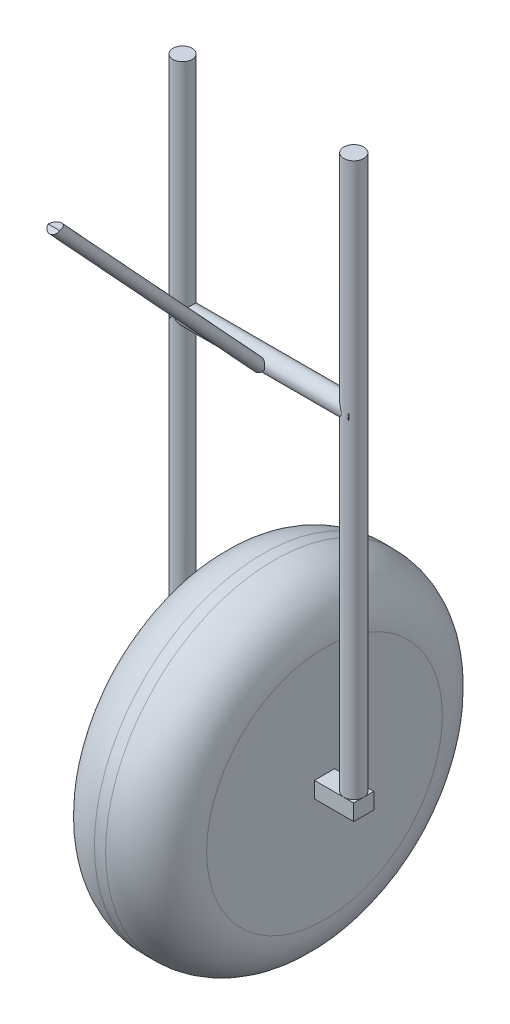
from build123d import *

# Parameters (mm, degrees)
IZIM1_R                          = 3
Y_KSEKLIK_EKSTR_ZYON1_DEPTH      = 1
Y_KSEKLIK_EKSTR_ZYON1_DEPTH_BACK = 1
RADYUS1_R                        = 0.9
RADYUS2_R                        = 0.9
IZIM2_W                          = 0.358194198
IZIM2_H                          = 0.28655536
Y_KSEKLIK_EKSTR_ZYON2_DEPTH      = 0.7
Y_KSEKLIK_EKSTR_ZYON2_DEPTH_BACK = 2.7
IZIM3_R                          = 0.171322749
IZIM3_R_2                        = 0.177674655
Y_KSEKLIK_EKSTR_ZYON3_DEPTH      = 10
IZIM5_R                          = 0.171322749
Y_KSEKLIK_EKSTR_ZYON4_DEPTH      = 1.6
Y_KSEKLIK_EKSTR_ZYON4_DEPTH_BACK = 1.6
KES_EKSTR_ZYON1_DEPTH            = 1.6


with BuildPart() as part:
    # izim1 → Y_kseklik-Ekstr_zyon1 (new body, two sides)
    with BuildSketch(Plane(origin=(0, 0, 0), x_dir=(0, 0, -1), z_dir=(1, 0, 0))) as y_kseklik_ekstr_zyon1_sk:
        Circle(IZIM1_R)
    extrude(amount=Y_KSEKLIK_EKSTR_ZYON1_DEPTH)
    extrude(y_kseklik_ekstr_zyon1_sk.sketch, amount=-Y_KSEKLIK_EKSTR_ZYON1_DEPTH_BACK)

    # Radyus1
    radyus1_edges = [part.edges().sort_by_distance(p)[0] for p in [
        (-1, 0, 3),
    ]]
    fillet(radyus1_edges, radius=RADYUS1_R)

    # Radyus2
    radyus2_edges = [part.edges().sort_by_distance(p)[0] for p in [
        (1, 0, 3),
    ]]
    fillet(radyus2_edges, radius=RADYUS2_R)

    # izim2 → Y_kseklik-Ekstr_zyon2 (add, two sides)
    with BuildSketch(Plane(origin=(1, 0, 0), x_dir=(0, 0, -1), z_dir=(1, 0, 0))) as y_kseklik_ekstr_zyon2_sk:
        Rectangle(IZIM2_W, IZIM2_H)
    extrude(amount=Y_KSEKLIK_EKSTR_ZYON2_DEPTH)
    extrude(y_kseklik_ekstr_zyon2_sk.sketch, amount=-Y_KSEKLIK_EKSTR_ZYON2_DEPTH_BACK)

    # izim3 → Y_kseklik-Ekstr_zyon3 (add)
    with BuildSketch(Plane(origin=(0, 0, 0), x_dir=(1, 0, 0), z_dir=(0, 1, 0))):
        with Locations((-1.529245006, 0)):
            Circle(IZIM3_R)
        with Locations((1.522325345, 0)):
            Circle(IZIM3_R_2)
    extrude(amount=Y_KSEKLIK_EKSTR_ZYON3_DEPTH)

    # izim5 → Y_kseklik-Ekstr_zyon4 (add, two sides)
    with BuildSketch(Plane(origin=(0, 0, 0), x_dir=(0, 0, -1), z_dir=(1, 0, 0))) as y_kseklik_ekstr_zyon4_sk:
        with Locations((0, 6.037482004)):
            Circle(IZIM5_R)
    extrude(amount=Y_KSEKLIK_EKSTR_ZYON4_DEPTH)
    extrude(y_kseklik_ekstr_zyon4_sk.sketch, amount=-Y_KSEKLIK_EKSTR_ZYON4_DEPTH_BACK)

    # izim6 → D_nd_r-_nce1 (revolve)
    with BuildSketch(Plane(origin=(0, 0, 0), x_dir=(0, 0, -1), z_dir=(1, 0, 0))):
        Polygon((-0.156029533, 6.037482004), (-3.82275516, 10), (-3.896152209, 9.932081863), (-0.229426581, 5.969563868), align=None)
    revolve(axis=Axis((0, 6.037482004, 0.156029533), (0, 0.733970484, 0.679181366)))

    # izim7 → Kes-Ekstr_zyon1 (cut)
    with BuildSketch(Plane(origin=(0, 10, 0), x_dir=(1, 0, 0), z_dir=(0, 1, 0))):
        Polygon((-0.387982537, -3.298594138), (-0.387982537, -3.511184794), (-0.387982537, -4.384499274), (0.201510503, -4.384499274), (0.201510503, -3.298594138), align=None)
    extrude(amount=KES_EKSTR_ZYON1_DEPTH, mode=Mode.SUBTRACT)


solid = part.part
